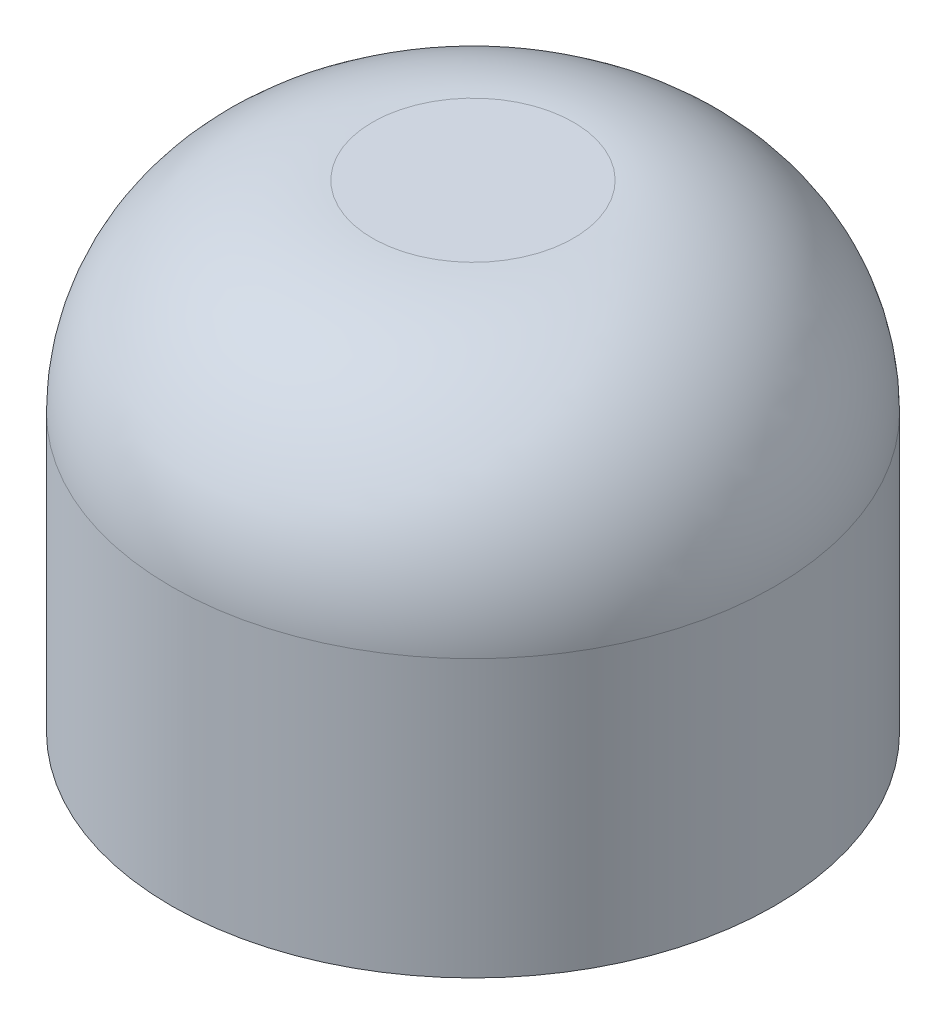
from build123d import *


with BuildPart() as part:
    # Schizzo1 → Rivoluzione1 (revolve)
    with BuildSketch(Plane.XY):
        with BuildLine():
            Line((0, 0), (1.5, 0))
            Line((1.5, 0), (1.5, -3))
            Line((1.5, -3), (3, -3))
            Line((3, -3), (3, -0.25))
            ThreePointArc((3, -0.25), (2.414213562, 1.164213562), (1, 1.75))
            Line((1, 1.75), (0, 1.75))
            Line((0, 1.75), (0, 0))
        make_face()
    revolve(axis=Axis((0, 1.75, 0), (0, -1, 0)))


solid = part.part
